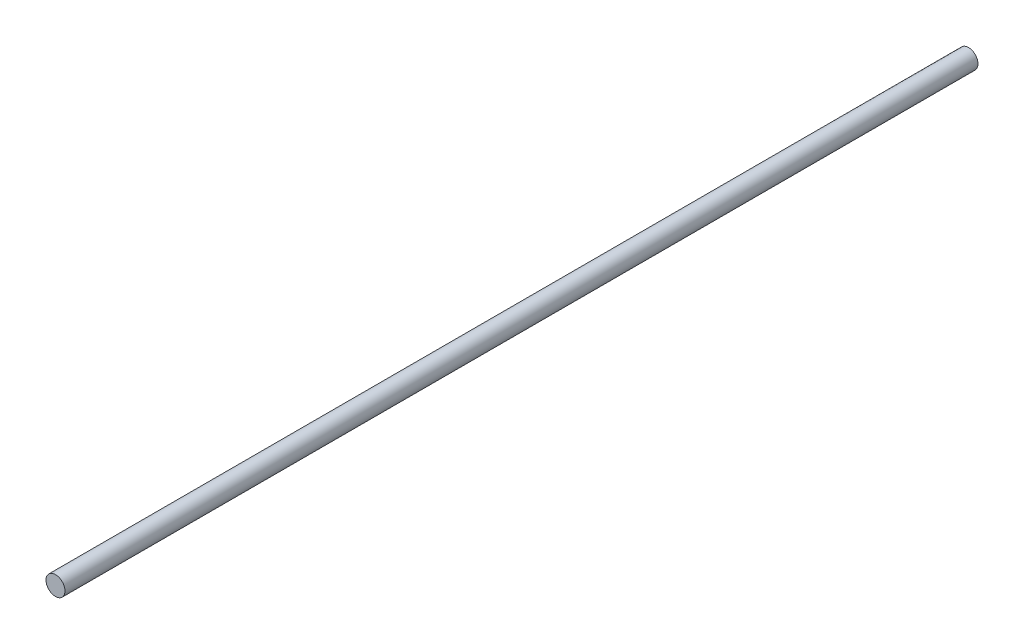
from build123d import *

# Parameters (mm, degrees)
ESQUISSE1_R = 4


with BuildPart() as part:
    # Balayage1: sweep along a path in Esquisse6
    with BuildLine(Plane(origin=(0, 0, 0), x_dir=(0, 0, -1), z_dir=(1, 0, 0))) as balayage1_path:
        Line((0, 0), (-384.499667553, 0))
    # Esquisse1 → Balayage1 (sweep)
    with BuildSketch(Plane.XY):
        Circle(ESQUISSE1_R)
    sweep(path=balayage1_path.line)


solid = part.part
